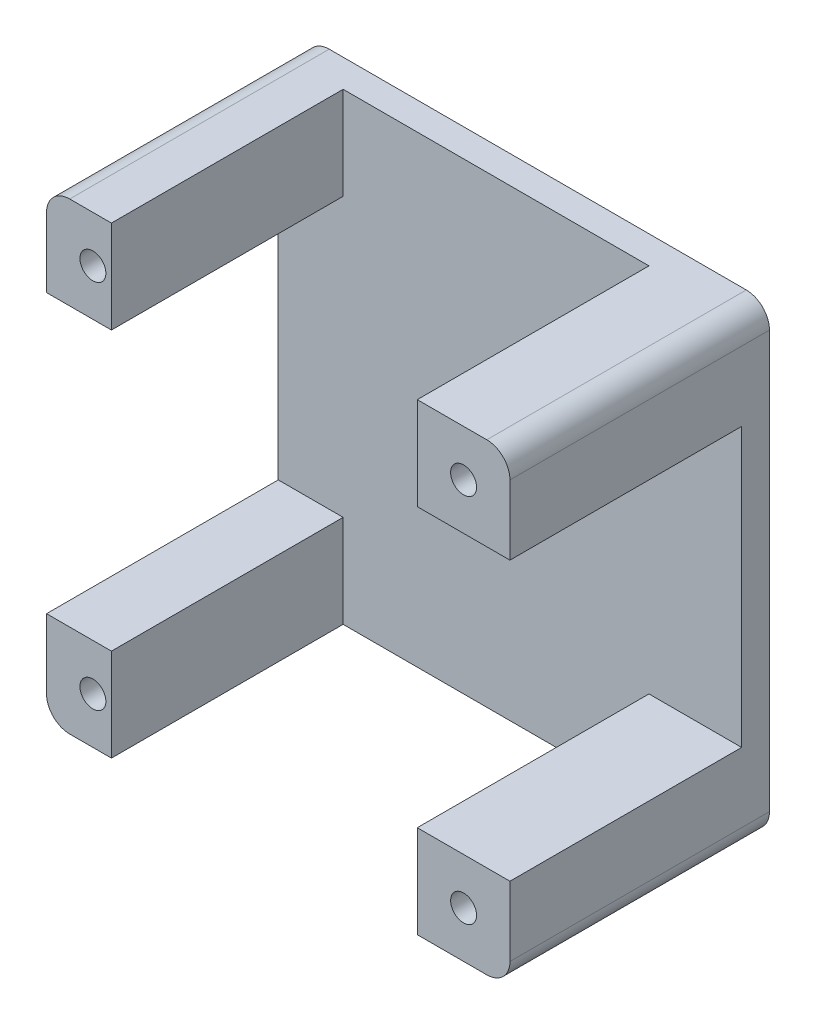
from build123d import *

# Parameters (mm, degrees)
BOSS_EXTRUDE1_DEPTH = 3
SKETCH1_3_R         = 1.4
BOSS_EXTRUDE2_DEPTH = 28


with BuildPart() as part:
    # Sketch1 → Boss-Extrude1 (new body)
    with BuildSketch(Plane.XY):
        Polygon((25.000000373, 15), (15, 15), (15, 25.000000373), (-18, 25.000000373), (-18, 15), (-25.000000373, 15), (-25.000000373, -15), (-18, -15), (-18, -25.000000373), (15, -25.000000373), (15, -15), (25.000000373, -15), align=None)
    extrude(amount=BOSS_EXTRUDE1_DEPTH)

    # Sketch1_3 → Boss-Extrude2 (add)
    # profile 1 of 4: a face of its own
    with BuildSketch(Plane.XY):
        with BuildLine():
            Line((15, 25.000000373), (15, 15))
            Line((15, 15), (25.000000373, 15))
            Line((25.000000373, 15), (25.000000373, 22.500000373))
            ThreePointArc((25.000000373, 22.500000373), (24.267767325, 24.267767325), (22.500000373, 25.000000373))
            Line((22.500000373, 25.000000373), (15, 25.000000373))
        make_face()
        with Locations((20, 20)):
            Circle(SKETCH1_3_R, mode=Mode.SUBTRACT)
    # profile 2 of 4: a face of its own
    with BuildSketch(Plane.XY):
        with BuildLine():
            Line((-18, 15), (-18, 25.000000373))
            Line((-18, 25.000000373), (-22.500000373, 25.000000373))
            ThreePointArc((-22.500000373, 25.000000373), (-24.267767325, 24.267767325), (-25.000000373, 22.500000373))
            Line((-25.000000373, 22.500000373), (-25.000000373, 15))
            Line((-25.000000373, 15), (-18, 15))
        make_face()
        with Locations((-20, 20)):
            Circle(SKETCH1_3_R, mode=Mode.SUBTRACT)
    # profile 3 of 4: a face of its own
    with BuildSketch(Plane.XY):
        with BuildLine():
            Line((25.000000373, -22.500000373), (25.000000373, -15))
            Line((25.000000373, -15), (15, -15))
            Line((15, -15), (15, -25.000000373))
            Line((15, -25.000000373), (22.500000373, -25.000000373))
            ThreePointArc((22.500000373, -25.000000373), (24.267767325, -24.267767325), (25.000000373, -22.500000373))
        make_face()
        with Locations((20, -20)):
            Circle(SKETCH1_3_R, mode=Mode.SUBTRACT)
    # profile 4 of 4: a face of its own
    with BuildSketch(Plane.XY):
        with BuildLine():
            Line((-22.500000373, -25.000000373), (-18, -25.000000373))
            Line((-18, -25.000000373), (-18, -15))
            Line((-18, -15), (-25.000000373, -15))
            Line((-25.000000373, -15), (-25.000000373, -22.500000373))
            ThreePointArc((-25.000000373, -22.500000373), (-24.267767325, -24.267767325), (-22.500000373, -25.000000373))
        make_face()
        with Locations((-20, -20)):
            Circle(SKETCH1_3_R, mode=Mode.SUBTRACT)
    extrude(amount=BOSS_EXTRUDE2_DEPTH)


solid = part.part
